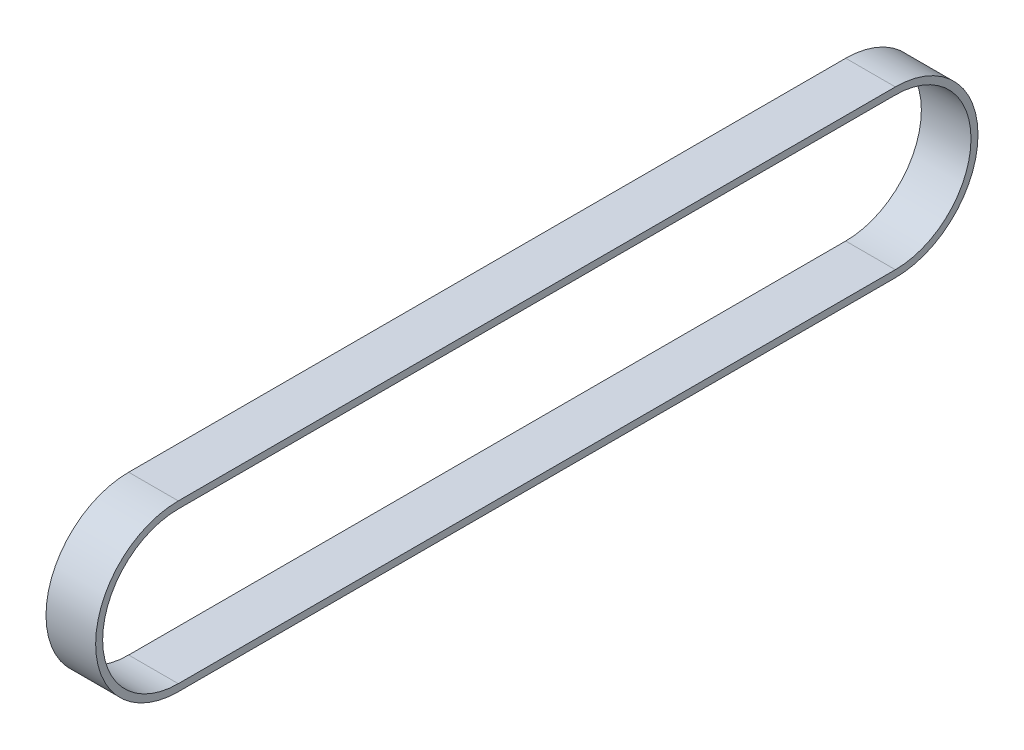
from build123d import *

# Parameters (mm, degrees)
EXTRUDE_THIN1_DEPTH = 9


with BuildPart() as part:
    # Sketch1 → Extrude-Thin1 (new body)
    with BuildSketch(Plane(origin=(0, 0, 0), x_dir=(0, 0, -1), z_dir=(1, 0, 0))):
        with BuildLine():
            Line((130, -14.986), (0, -14.986))
            ThreePointArc((0, -14.986), (-14.986, 0), (0, 14.986))
            Line((0, 14.986), (130, 14.986))
            ThreePointArc((130, 14.986), (144.986, 0), (130, -14.986))
        make_face()
        with BuildLine():
            Line((130, -13.716), (0, -13.716))
            ThreePointArc((0, -13.716), (-13.716, 0), (0, 13.716))
            Line((0, 13.716), (130, 13.716))
            ThreePointArc((130, 13.716), (143.716, 0), (130, -13.716))
        make_face(mode=Mode.SUBTRACT)
    extrude(amount=EXTRUDE_THIN1_DEPTH)


solid = part.part
